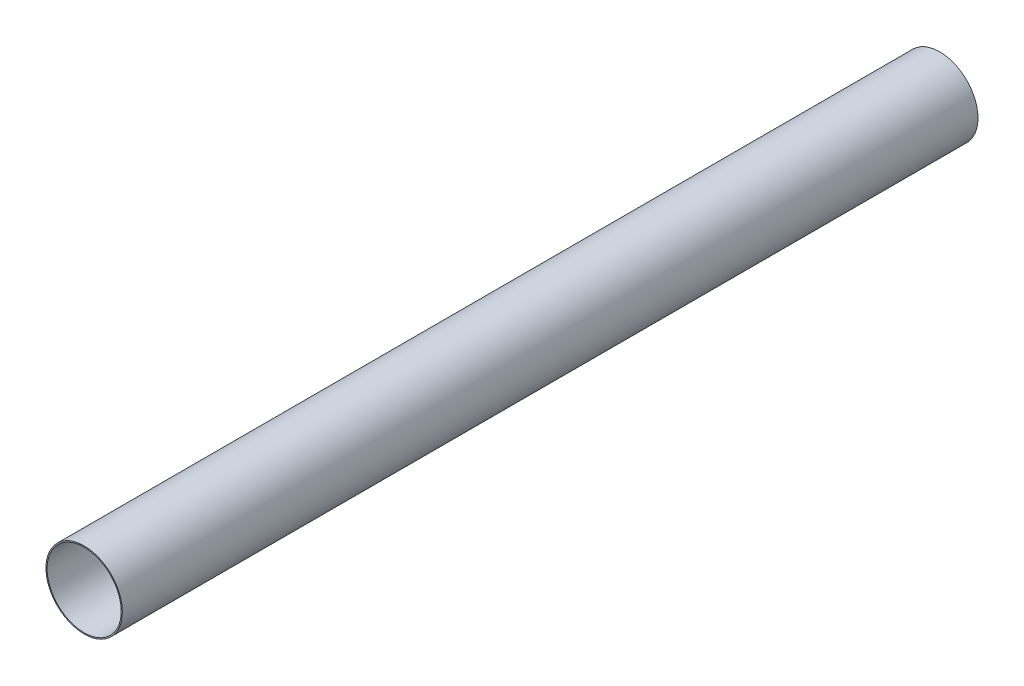
from build123d import *

# Parameters (mm, degrees)
SKETCH1_R           = 51.054
SKETCH1_R_2         = 49.53
BOSS_EXTRUDE1_DEPTH = 1143


with BuildPart() as part:
    # Sketch1 → Boss-Extrude1 (new body)
    with BuildSketch(Plane.XY):
        Circle(SKETCH1_R)
        Circle(SKETCH1_R_2, mode=Mode.SUBTRACT)
    extrude(amount=BOSS_EXTRUDE1_DEPTH)


solid = part.part
